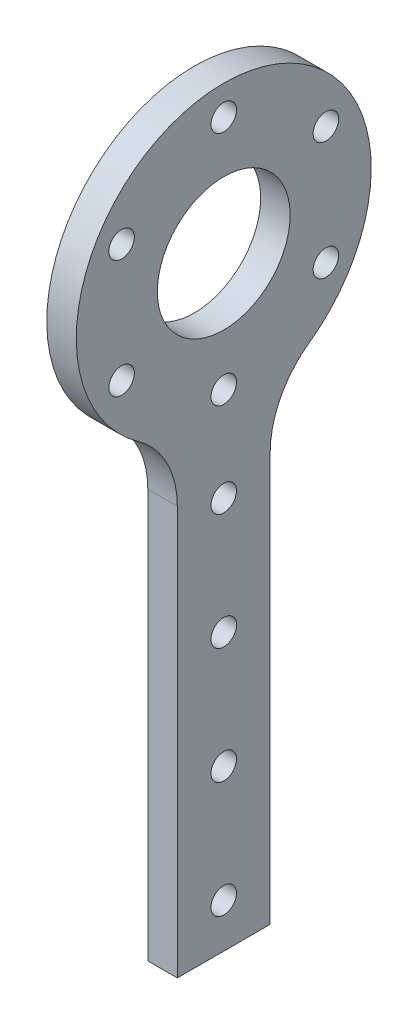
from build123d import *

# Parameters (mm, degrees)
BOSS_EXTRUDE1_DEPTH = 6.35
FILLET1_R           = 20
SKETCH2_R           = 14.3
SKETCH2_R_2         = 2.75
CUT_EXTRUDE1_DEPTH  = 7.35
SKETCH3_R           = 2.75
CUT_EXTRUDE2_DEPTH  = 7.35


with BuildPart() as part:
    # Sketch1 → Boss-Extrude1 (new body)
    with BuildSketch(Plane(origin=(0, 0, 0), x_dir=(0, 0, -1), z_dir=(1, 0, 0))):
        with BuildLine():
            Line((-10, -30.134075396), (-10, -130.134075396))
            Line((-10, -130.134075396), (10, -130.134075396))
            Line((10, -130.134075396), (10, -30.134075396))
            ThreePointArc((10, -30.134075396), (0, 31.75), (-10, -30.134075396))
        make_face()
    extrude(amount=BOSS_EXTRUDE1_DEPTH)

    # Fillet1
    fillet1_edges = [part.edges().sort_by_distance(p)[0] for p in [
        (3.175, -30.134075396, -10),
        (3.175, -30.134075396, 10),
    ]]
    fillet(fillet1_edges, radius=FILLET1_R)

    # Sketch2 → Cut-Extrude1 (cut, through all)
    with BuildSketch(Plane(origin=(6.35, 0, 0), x_dir=(0, 0, -1), z_dir=(1, 0, 0))):
        Circle(SKETCH2_R)
        with Locations((0, 25.4)):
            Circle(SKETCH2_R_2)
        with Locations((21.997045256, 12.7)):
            Circle(SKETCH2_R_2)
        with Locations((21.997045256, -12.7)):
            Circle(SKETCH2_R_2)
        with Locations((0, -25.4)):
            Circle(SKETCH2_R_2)
        with Locations((-21.997045256, -12.7)):
            Circle(SKETCH2_R_2)
        with Locations((-21.997045256, 12.7)):
            Circle(SKETCH2_R_2)
    extrude(amount=-CUT_EXTRUDE1_DEPTH, mode=Mode.SUBTRACT)

    # Sketch3 → Cut-Extrude2 (cut, through all)
    with BuildSketch(Plane(origin=(6.35, 0, 0), x_dir=(0, 0, -1), z_dir=(1, 0, 0))):
        with Locations((0, -120.63662428)):
            Circle(SKETCH3_R)
        with Locations((0, -95.63662428)):
            Circle(SKETCH3_R)
        with Locations((0, -70.63662428)):
            Circle(SKETCH3_R)
        with Locations((0, -45.63662428)):
            Circle(SKETCH3_R)
    extrude(amount=-CUT_EXTRUDE2_DEPTH, mode=Mode.SUBTRACT)


solid = part.part
